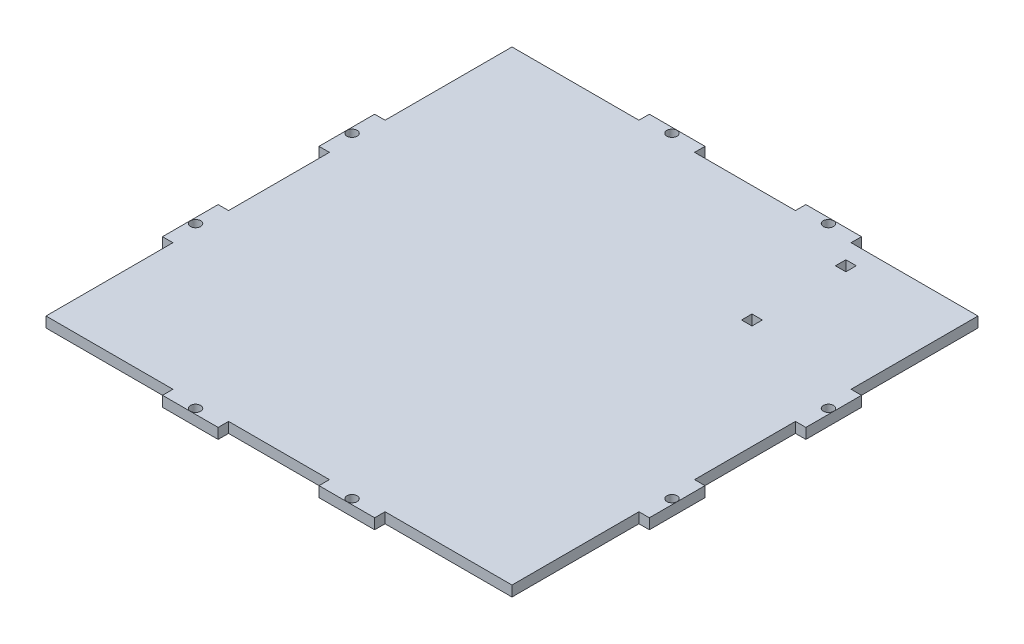
from build123d import *

# Parameters (mm, degrees)
BOSS_EXTRUDE1_DEPTH = 3
SKETCH2_W           = 3
SKETCH2_H           = 3
SKETCH2_H_2         = 36.5
SKETCH2_W_2         = 36.5
SKETCH2_W_3         = 29
SKETCH2_H_3         = 29
CUT_EXTRUDE2_DEPTH  = 3
SKETCH3_R           = 1.47
CUT_EXTRUDE3_DEPTH  = 3
SKETCH4_W           = 3
SKETCH4_H           = 3
CUT_EXTRUDE4_DEPTH  = 3


with BuildPart() as part:
    # Sketch1 → Boss-Extrude1 (new body)
    with BuildSketch(Plane(origin=(0, 0, 0), x_dir=(1, 0, 0), z_dir=(0, 1, 0))):
        Polygon((70, 70), (-70, 70), (0, 0), align=None)
        Polygon((0, 0), (-70, 70), (-70, -70), align=None)
        Polygon((70, -70), (0, 0), (-70, -70), align=None)
        Polygon((70, 70), (0, 0), (70, -70), align=None)
    extrude(amount=BOSS_EXTRUDE1_DEPTH)

    # Sketch2 → Cut-Extrude2 (cut)
    with BuildSketch(Plane(origin=(0, 3, 0), x_dir=(1, 0, 0), z_dir=(0, 1, 0))):
        with Locations((-68.5, 68.5)):
            Rectangle(SKETCH2_W, SKETCH2_H)
        with Locations((-68.5, 48.75)):
            Rectangle(SKETCH2_W, SKETCH2_H_2)
        with Locations((-48.75, 68.5)):
            Rectangle(SKETCH2_W_2, SKETCH2_H)
        with Locations((48.75, 68.5)):
            Rectangle(SKETCH2_W_2, SKETCH2_H)
        with Locations((68.5, 68.5)):
            Rectangle(SKETCH2_W, SKETCH2_H)
        with Locations((68.5, 48.75)):
            Rectangle(SKETCH2_W, SKETCH2_H_2)
        with Locations((68.5, -68.5)):
            Rectangle(SKETCH2_W, SKETCH2_H)
        with Locations((68.5, -48.75)):
            Rectangle(SKETCH2_W, SKETCH2_H_2)
        with Locations((48.75, -68.5)):
            Rectangle(SKETCH2_W_2, SKETCH2_H)
        with Locations((-48.75, -68.5)):
            Rectangle(SKETCH2_W_2, SKETCH2_H)
        with Locations((-68.5, -68.5)):
            Rectangle(SKETCH2_W, SKETCH2_H)
        with Locations((-68.5, -48.75)):
            Rectangle(SKETCH2_W, SKETCH2_H_2)
        with Locations((0, 68.5)):
            Rectangle(SKETCH2_W_3, SKETCH2_H)
        with Locations((0, -68.5)):
            Rectangle(SKETCH2_W_3, SKETCH2_H)
        with Locations((68.5, 0)):
            Rectangle(SKETCH2_W, SKETCH2_H_3)
        with Locations((-68.5, 0)):
            Rectangle(SKETCH2_W, SKETCH2_H_3)
    extrude(amount=-CUT_EXTRUDE2_DEPTH, mode=Mode.SUBTRACT)

    # Sketch3 → Cut-Extrude3 (cut)
    with BuildSketch(Plane(origin=(0, 3, 0), x_dir=(1, 0, 0), z_dir=(0, 1, 0))):
        with Locations((-22.5, 68.5)):
            Circle(SKETCH3_R)
        with Locations((22.5, 68.5)):
            Circle(SKETCH3_R)
        with Locations((22.5, -68.5)):
            Circle(SKETCH3_R)
        with Locations((-22.5, -68.5)):
            Circle(SKETCH3_R)
        with Locations((-68.5, 22.5)):
            Circle(SKETCH3_R)
        with Locations((-68.5, -22.5)):
            Circle(SKETCH3_R)
        with Locations((68.5, -22.5)):
            Circle(SKETCH3_R)
        with Locations((68.5, 22.5)):
            Circle(SKETCH3_R)
    extrude(amount=-CUT_EXTRUDE3_DEPTH, mode=Mode.SUBTRACT)

    # Sketch4 → Cut-Extrude4 (cut)
    with BuildSketch(Plane(origin=(0, 3, 0), x_dir=(1, 0, 0), z_dir=(0, 1, 0))):
        with Locations((35.5, 60.5)):
            Rectangle(SKETCH4_W, SKETCH4_H)
        with Locations((35.5, 33.5)):
            Rectangle(SKETCH4_W, SKETCH4_H)
    extrude(amount=-CUT_EXTRUDE4_DEPTH, mode=Mode.SUBTRACT)


solid = part.part
